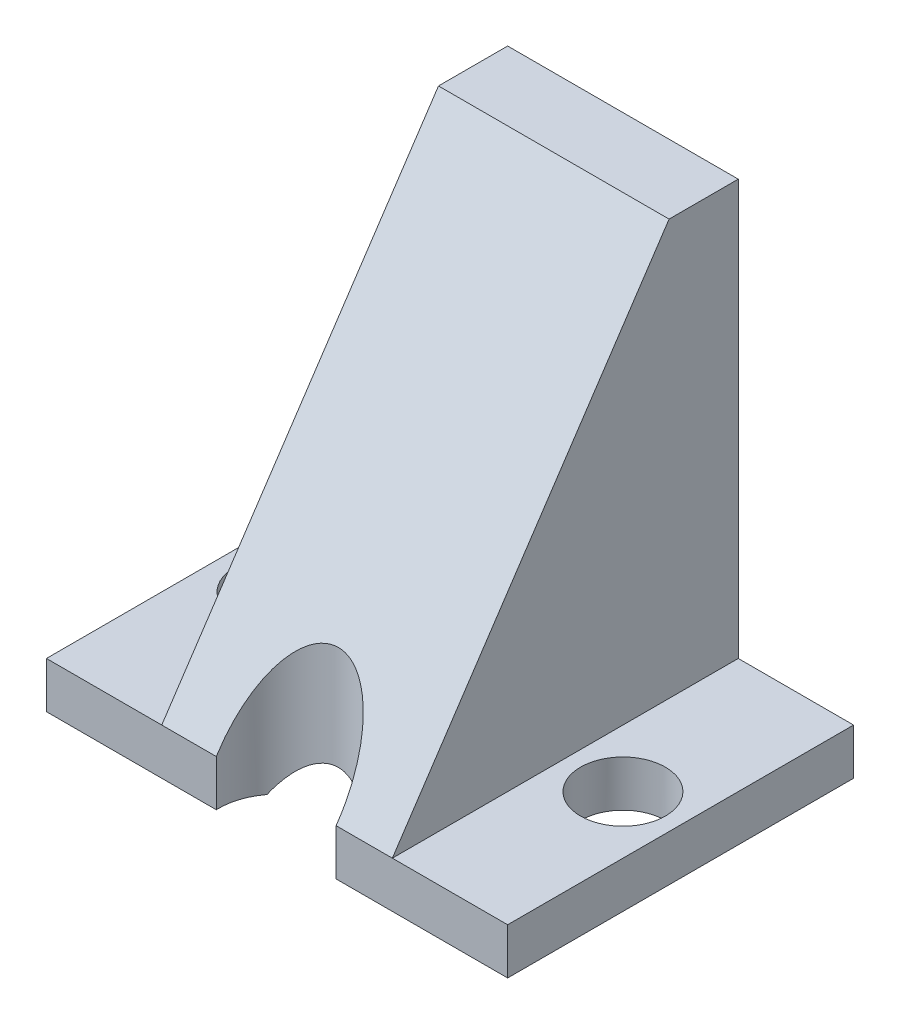
from build123d import *

# Parameters (mm, degrees)
SKETCH1_W           = 25.4
SKETCH1_H           = 19.05
BOSS_EXTRUDE1_DEPTH = 25.4
CHAMFER1_SIZE       = 22.86
CHAMFER1_SIZE2      = 15.24
SKETCH2_W           = 6.35
SKETCH2_H           = 22.78915262
CUT_EXTRUDE1_DEPTH  = 22.86
SKETCH3_W           = 9.652
SKETCH3_H           = 39.353766532
CUT_EXTRUDE2_DEPTH  = 22.86
SKETCH4_R           = 2.3368
CUT_EXTRUDE3_DEPTH  = 22.86
SKETCH6_R           = 3.302
CUT_EXTRUDE5_DEPTH  = 26.4


with BuildPart() as part:
    # Sketch1 → Boss-Extrude1 (new body)
    with BuildSketch(Plane(origin=(0, 0, 0), x_dir=(1, 0, 0), z_dir=(0, 1, 0))):
        with Locations((12.7, 9.525)):
            Rectangle(SKETCH1_W, SKETCH1_H)
    extrude(amount=BOSS_EXTRUDE1_DEPTH)

    # Chamfer1
    chamfer1_edges = [part.edges().sort_by_distance(p)[0] for p in [
        (12.7, 25.4, 0),
    ]]
    chamfer1_side = [part.faces().sort_by_distance(p)[0] for p in [
        (12.7, 12.7, 0),
    ]]
    chamfer(chamfer1_edges, length=CHAMFER1_SIZE, length2=CHAMFER1_SIZE2, reference=chamfer1_side[0])

    # Sketch2 → Cut-Extrude1 (cut)
    with BuildSketch(Plane(origin=(0, 25.4, 0), x_dir=(1, 0, 0), z_dir=(0, 1, 0))):
        with Locations((22.225, 7.65542369)):
            Rectangle(SKETCH2_W, SKETCH2_H)
        with Locations((3.175, 7.65542369)):
            Rectangle(SKETCH2_W, SKETCH2_H)
    extrude(amount=-CUT_EXTRUDE1_DEPTH, mode=Mode.SUBTRACT)

    # Sketch3 → Cut-Extrude2 (cut)
    with BuildSketch(Plane(origin=(0, -0.979634661, -1.469451992), x_dir=(1, 0, 0), z_dir=(0, 0.554700196, 0.832050294))):
        with Locations((12.7, 14.647750361)):
            Rectangle(SKETCH3_W, SKETCH3_H)
    extrude(amount=-CUT_EXTRUDE2_DEPTH, mode=Mode.SUBTRACT)

    # Sketch4 → Cut-Extrude3 (cut)
    with BuildSketch(Plane(origin=(0, 2.54, 0), x_dir=(1, 0, 0), z_dir=(0, 1, 0))):
        with Locations((3.175, 9.525)):
            Circle(SKETCH4_R)
        with Locations((22.225, 9.525)):
            Circle(SKETCH4_R)
    extrude(amount=-CUT_EXTRUDE3_DEPTH, mode=Mode.SUBTRACT)

    # Sketch6 → Cut-Extrude5 (cut, through all)
    with BuildSketch(Plane.XZ):
        with Locations((12.652625, -0.124494929)):
            Circle(SKETCH6_R)
    extrude(amount=-CUT_EXTRUDE5_DEPTH, mode=Mode.SUBTRACT)


solid = part.part
